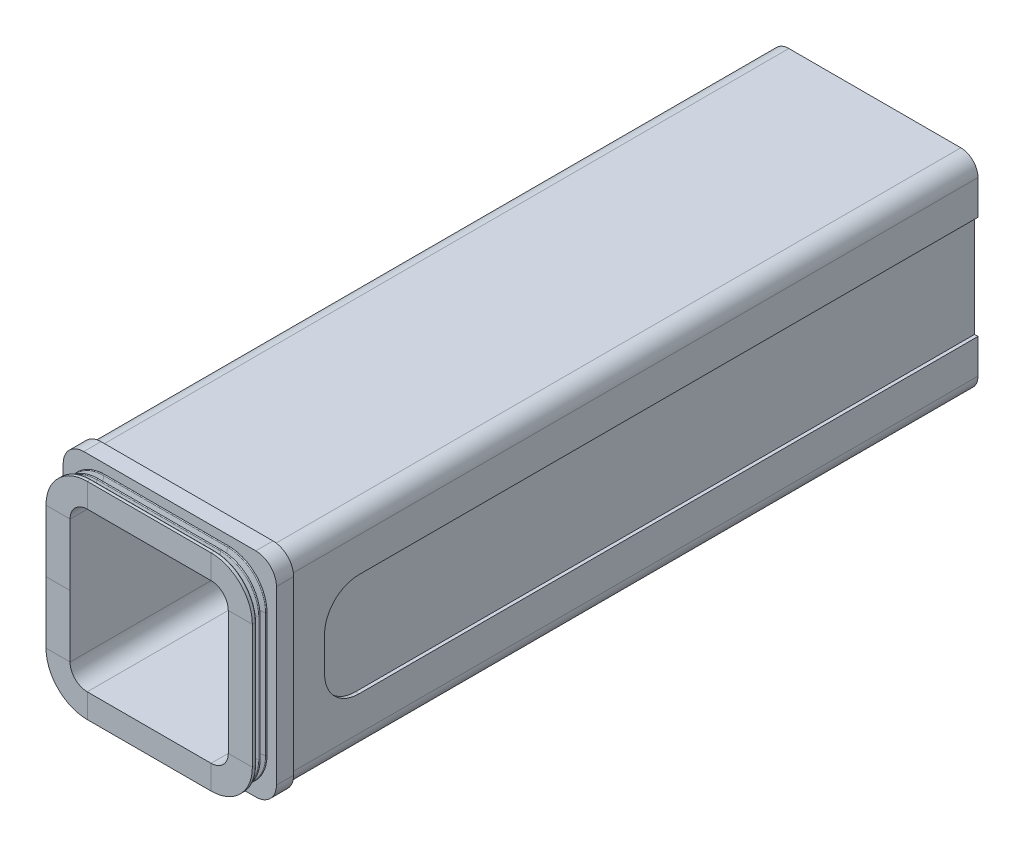
from build123d import *

# Parameters (mm, degrees)
BOSS_EXTRUDE1_DEPTH  = 200
BOSS_EXTRUDE2_DEPTH  = 5
CUT_EXTRUDE1_DEPTH   = 206
SKETCH7_W            = 190
SKETCH7_H            = 30
CUT_EXTRUDE2_DEPTH   = 1
FILLET1_R            = 10
FILLET1_OF_MIRROR1_R = 10


with BuildPart() as part:
    # Sketch1 → Boss-Extrude1 (new body)
    with BuildSketch(Plane.XY):
        with BuildLine():
            Line((-25, -30), (25, -30))
            ThreePointArc((25, -30), (28.535533906, -28.535533906), (30, -25))
            Line((30, -25), (30, 25))
            ThreePointArc((30, 25), (28.535533906, 28.535533906), (25, 30))
            Line((25, 30), (-25, 30))
            ThreePointArc((-25, 30), (-28.535533906, 28.535533906), (-30, 25))
            Line((-30, 25), (-30, -25))
            ThreePointArc((-30, -25), (-28.535533906, -28.535533906), (-25, -30))
        make_face()
    extrude(amount=BOSS_EXTRUDE1_DEPTH)

    # Sketch2 → Boss-Extrude2 (add)
    with BuildSketch(Plane.XY.offset(200)):
        with BuildLine():
            Line((-25, -31), (25, -31))
            ThreePointArc((25, -31), (29.242640687, -29.242640687), (31, -25))
            Line((31, -25), (31, 25))
            ThreePointArc((31, 25), (29.242640687, 29.242640687), (25, 31))
            Line((25, 31), (-25, 31))
            ThreePointArc((-25, 31), (-29.242640687, 29.242640687), (-31, 25))
            Line((-31, 25), (-31, -25))
            ThreePointArc((-31, -25), (-29.242640687, -29.242640687), (-25, -31))
        make_face()
    extrude(amount=BOSS_EXTRUDE2_DEPTH)

    # Sweep1: sweep along a path in Sketch5
    with BuildLine(Plane.XY.offset(205)) as sweep1_path:
        Line((18, -23), (-18, -23))
        ThreePointArc((-18, -23), (-21.535533906, -21.535533906), (-23, -18))
        Line((-23, -18), (-23, 18))
        ThreePointArc((-23, 18), (-21.535533906, 21.535533906), (-18, 23))
        Line((-18, 23), (18, 23))
        ThreePointArc((18, 23), (21.535533906, 21.535533906), (23, 18))
        Line((23, 18), (23, -18))
        ThreePointArc((23, -18), (21.535533906, -21.535533906), (18, -23))
    # Sketch3 → Sweep1 (sweep)
    with BuildSketch(Plane(origin=(0, 0, 0), x_dir=(1, 0, 0), z_dir=(0, 1, 0))):
        with BuildLine():
            Line((-25, -205), (-29.019419324, -205.803883865))
            ThreePointArc((-29.019419324, -205.803883865), (-29.180196097, -206), (-29.019419324, -206.196116135))
            Line((-29.019419324, -206.196116135), (-25.980580676, -206.803883865))
            ThreePointArc((-25.980580676, -206.803883865), (-25.819803903, -207), (-25.980580676, -207.196116135))
            Line((-25.980580676, -207.196116135), (-29.019419324, -207.803883865))
            ThreePointArc((-29.019419324, -207.803883865), (-29.180196097, -208), (-29.019419324, -208.196116135))
            Line((-29.019419324, -208.196116135), (-25.980580676, -208.803883865))
            ThreePointArc((-25.980580676, -208.803883865), (-25.819803903, -209), (-25.980580676, -209.196116135))
            Line((-25.980580676, -209.196116135), (-29.839223227, -209.967844645))
            ThreePointArc((-29.839223227, -209.967844645), (-29.954668428, -210.037162999), (-30, -210.163960781))
            Line((-30, -210.163960781), (-30, -211))
            Line((-30, -211), (-23, -211))
            Line((-23, -211), (-23, -205))
            Line((-23, -205), (-25, -205))
        make_face()
    sweep(path=sweep1_path.line)

    # Sketch6 → Cut-Extrude1 (cut, through all)
    with BuildSketch(Plane.XY.offset(205)):
        with BuildLine():
            Line((-23, 18), (-23, 0))
            Line((-23, 0), (-23, -18))
            ThreePointArc((-23, -18), (-21.535533906, -21.535533906), (-18, -23))
            Line((-18, -23), (18, -23))
            ThreePointArc((18, -23), (21.535533906, -21.535533906), (23, -18))
            Line((23, -18), (23, 18))
            ThreePointArc((23, 18), (21.535533906, 21.535533906), (18, 23))
            Line((18, 23), (-18, 23))
            ThreePointArc((-18, 23), (-21.535533906, 21.535533906), (-23, 18))
        make_face()
    extrude(amount=-CUT_EXTRUDE1_DEPTH, mode=Mode.SUBTRACT)

    # Sketch7 → Cut-Extrude2 (cut)
    with BuildSketch(Plane.ZY.offset(30)):
        with Locations((95, 0)):
            Rectangle(SKETCH7_W, SKETCH7_H)
    cut_extrude2 = extrude(amount=-CUT_EXTRUDE2_DEPTH, mode=Mode.SUBTRACT)

    # Fillet1
    fillet1_edges = [part.edges().sort_by_distance(p)[0] for p in [
        (-29.5, -15, 190),
        (-29.5, 15, 190),
    ]]
    fillet(fillet1_edges, radius=FILLET1_R)

    # Mirror1: Cut-Extrude2 across plane
    add(cut_extrude2.mirror(Plane.ZY), mode=Mode.SUBTRACT)

    # Fillet1 of Mirror1
    fillet1_of_mirror1_edges = [part.edges().sort_by_distance(p)[0] for p in [
        (29.5, -15, 190),
        (29.5, 15, 190),
    ]]
    fillet(fillet1_of_mirror1_edges, radius=FILLET1_OF_MIRROR1_R)


solid = part.part
